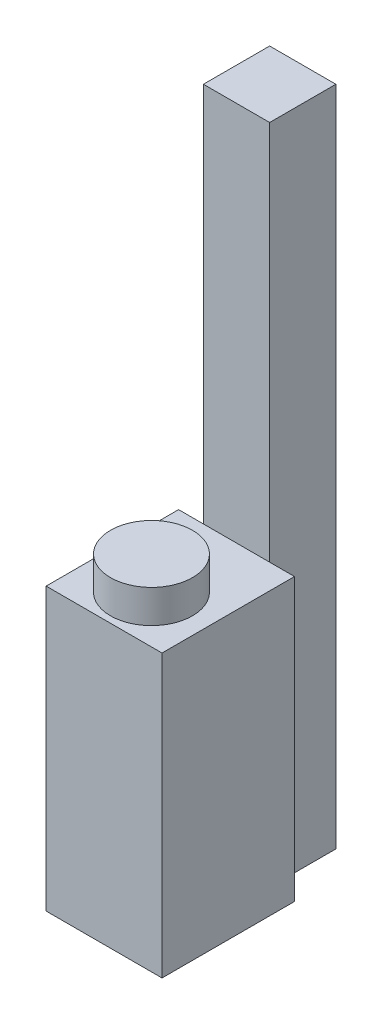
from build123d import *

# Parameters (mm, degrees)
SKIZZE1_W                       = 35
SKIZZE1_H                       = 85
AUFSATZ_LINEAR_AUSTRAGEN1_DEPTH = 40
SKIZZE2_R                       = 12.384443891
AUFSATZ_LINEAR_AUSTRAGEN2_DEPTH = 10
SKIZZE3_W                       = 20
SKIZZE3_H                       = 200
AUFSATZ_LINEAR_AUSTRAGEN3_DEPTH = 20


with BuildPart() as part:
    # Skizze1 → Aufsatz-Linear austragen1 (new body)
    with BuildSketch(Plane.XY):
        Rectangle(SKIZZE1_W, SKIZZE1_H)
    extrude(amount=-AUFSATZ_LINEAR_AUSTRAGEN1_DEPTH)

    # Skizze2 → Aufsatz-Linear austragen2 (add)
    with BuildSketch(Plane(origin=(0, 42.5, 0), x_dir=(1, 0, 0), z_dir=(0, 1, 0))):
        with Locations((0, 14.316526297)):
            Circle(SKIZZE2_R)
    extrude(amount=AUFSATZ_LINEAR_AUSTRAGEN2_DEPTH)

    # Skizze3 → Aufsatz-Linear austragen3 (add)
    with BuildSketch(Plane(origin=(0, 0, -40), x_dir=(-1, 0, 0), z_dir=(0, 0, -1))):
        with Locations((0, 57.5)):
            Rectangle(SKIZZE3_W, SKIZZE3_H)
    extrude(amount=AUFSATZ_LINEAR_AUSTRAGEN3_DEPTH)


solid = part.part
